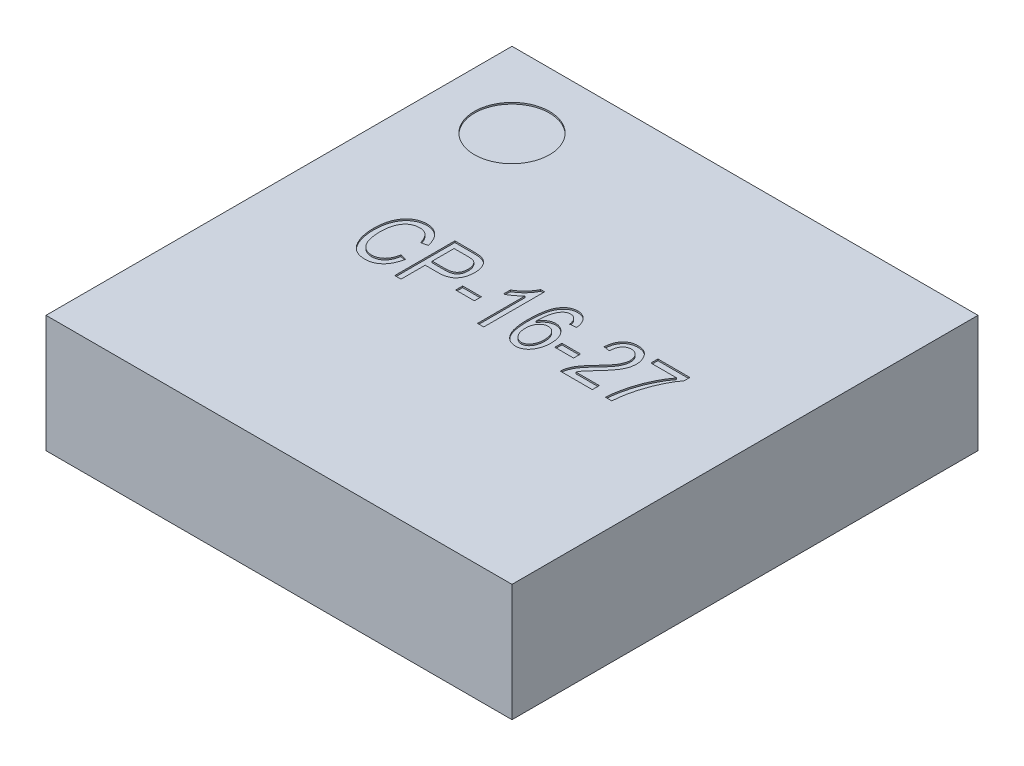
from build123d import *

# Parameters (mm, degrees)
SKETCH1_W           = 3.1
SKETCH1_H           = 3.1
BOSS_EXTRUDE1_DEPTH = 0.78
SKETCH2_R           = 0.25
CUT_EXTRUDE1_DEPTH  = 0.01
SKETCH3_W           = 0.124675325
SKETCH3_H           = 0.046753246
SKETCH3_W_2         = 0.124675324
CUT_EXTRUDE2_DEPTH  = 0.01


with BuildPart() as part:
    # Sketch1 → Boss-Extrude1 (new body)
    with BuildSketch(Plane(origin=(0, 0, 0), x_dir=(1, 0, 0), z_dir=(0, 1, 0))):
        Rectangle(SKETCH1_W, SKETCH1_H)
    extrude(amount=BOSS_EXTRUDE1_DEPTH)

    # Sketch2 → Cut-Extrude1 (cut)
    with BuildSketch(Plane(origin=(0, 0.78, 0), x_dir=(1, 0, 0), z_dir=(0, 1, 0))):
        with Locations(Location((-1.05, 1.05, 0), (0, 0, 270))):
            Circle(SKETCH2_R)
    extrude(amount=-CUT_EXTRUDE1_DEPTH, mode=Mode.SUBTRACT)

    # Sketch3 → Cut-Extrude2 (cut)
    with BuildSketch(Plane(origin=(0, 0.78, 0), x_dir=(1, 0, 0), z_dir=(0, 1, 0))):
        with BuildLine():
            Line((-0.717673959, -0.020779948), (-0.676115518, -0.031169558))
            add(Edge.make_bspline(
                [(-0.676115518, -0.031169558), (-0.677354174, -0.036676814), (-0.679769038, -0.047413667), (-0.684298524, -0.062856768), (-0.689591329, -0.077189165), (-0.695502514, -0.090465155), (-0.702079477, -0.102686775), (-0.709289846, -0.113845617), (-0.717194315, -0.123932561), (-0.725832256, -0.132823394), (-0.734915321, -0.140800826), (-0.744655072, -0.147497105), (-0.754758483, -0.153365781), (-0.765418597, -0.158039928), (-0.776527815, -0.161742072), (-0.788145945, -0.164295984), (-0.800225781, -0.166007418), (-0.808468802, -0.166158177), (-0.812641492, -0.166234493)],
                knots=[0, 0, 0, 0, 1.289221957, 2.51344498, 3.673011535, 4.776835723, 5.830430132, 6.840130389, 7.808269491, 8.7523986, 9.668123701, 10.564817631, 11.447926293, 12.333367568, 13.218722559, 14.118350969, 15.047492789, 16, 16, 16, 16], degree=3))
            add(Edge.make_bspline(
                [(-0.812641492, -0.166234493), (-0.81632424, -0.166183676), (-0.823543289, -0.166084064), (-0.834167116, -0.164958006), (-0.844408057, -0.163313188), (-0.854242401, -0.160836879), (-0.863691814, -0.157805377), (-0.872665062, -0.153912047), (-0.881307951, -0.149481171), (-0.889521557, -0.14424478), (-0.897403466, -0.138312627), (-0.904742149, -0.131415268), (-0.911892587, -0.12387567), (-0.918488354, -0.115333566), (-0.924977175, -0.106129517), (-0.930810714, -0.095919385), (-0.936469943, -0.085001883), (-0.941681628, -0.073289224), (-0.946535965, -0.060899189), (-0.950500155, -0.047813383), (-0.954035766, -0.034259551), (-0.956841804, -0.020132643), (-0.959157024, -0.005491351), (-0.960623158, 0.009743789), (-0.961659393, 0.02549902), (-0.961772365, 0.036198775), (-0.961829804, 0.041638884)],
                knots=[0, 0, 0, 0, 0.921095259, 1.805562833, 2.670327692, 3.514278933, 4.340642213, 5.150451062, 5.958900505, 6.768369716, 7.58482939, 8.423223242, 9.285360719, 10.181948201, 11.120907027, 12.10087379, 13.121233649, 14.196976745, 15.307105309, 16.44839936, 17.61583717, 18.810746038, 20.050660639, 21.323136918, 22.638994396, 24, 24, 24, 24], degree=3))
            add(Edge.make_bspline(
                [(-0.961829804, 0.041638884), (-0.961772834, 0.046997877), (-0.961661099, 0.057508534), (-0.960626561, 0.072939476), (-0.959164157, 0.087770654), (-0.956840779, 0.101951163), (-0.954053936, 0.115542709), (-0.950531524, 0.128454837), (-0.946508013, 0.140793776), (-0.941723576, 0.152441526), (-0.936332132, 0.163407368), (-0.930570922, 0.173736932), (-0.924426592, 0.183431155), (-0.917758506, 0.192390728), (-0.910602263, 0.200593407), (-0.903015944, 0.208121334), (-0.894960156, 0.214927688), (-0.886528111, 0.221135633), (-0.877692098, 0.226516011), (-0.868634351, 0.231294088), (-0.859286729, 0.235258605), (-0.849683347, 0.238516414), (-0.839833487, 0.241048803), (-0.829733439, 0.242789944), (-0.819408636, 0.244018013), (-0.812428714, 0.244109146), (-0.808907726, 0.244155117)],
                knots=[0, 0, 0, 0, 1.355009242, 2.657595594, 3.909622363, 5.12221665, 6.289669639, 7.416642245, 8.504963989, 9.569716403, 10.597874851, 11.593392335, 12.559484071, 13.498222117, 14.414780627, 15.309839368, 16.198178116, 17.079506653, 17.954919271, 18.811820418, 19.667108407, 20.519600343, 21.37423126, 22.235899437, 23.110108003, 24, 24, 24, 24], degree=3))
            add(Edge.make_bspline(
                [(-0.808907726, 0.244155117), (-0.8050623, 0.24405556), (-0.797508578, 0.243859996), (-0.786351382, 0.242490504), (-0.775678273, 0.239999719), (-0.765309714, 0.236790752), (-0.755440282, 0.232452785), (-0.745942459, 0.22723389), (-0.736899084, 0.221024065), (-0.728304253, 0.21386156), (-0.720167297, 0.205835035), (-0.71267253, 0.196860406), (-0.705888371, 0.186977463), (-0.699551163, 0.176324582), (-0.694092991, 0.164642114), (-0.689171716, 0.152135505), (-0.684691013, 0.138783402), (-0.682456143, 0.129456504), (-0.681310323, 0.124674598)],
                knots=[0, 0, 0, 0, 0.969230344, 1.90389736, 2.827024372, 3.728538081, 4.635631584, 5.539103428, 6.456494714, 7.396000419, 8.355610671, 9.333534695, 10.338037519, 11.374284513, 12.454112223, 13.583699076, 14.761161004, 16, 16, 16, 16], degree=3))
            Line((-0.681310323, 0.124674598), (-0.722868765, 0.114284988))
            add(Edge.make_bspline(
                [(-0.722868765, 0.114284988), (-0.72380807, 0.1176505), (-0.725639998, 0.124214261), (-0.728899965, 0.133641822), (-0.732465473, 0.142425695), (-0.736340493, 0.150589596), (-0.740655642, 0.158062682), (-0.745284801, 0.164905852), (-0.750235891, 0.171138158), (-0.755612907, 0.176628184), (-0.761236894, 0.181581722), (-0.76728019, 0.185825198), (-0.773692617, 0.18937023), (-0.780416229, 0.192350261), (-0.787472275, 0.194591776), (-0.794883956, 0.196242816), (-0.802631572, 0.197216684), (-0.807930987, 0.197339653), (-0.810612271, 0.197401871)],
                knots=[0, 0, 0, 0, 1.274827499, 2.486296693, 3.637698816, 4.732866786, 5.781146847, 6.783409552, 7.745577291, 8.681189198, 9.583979081, 10.476943643, 11.369744444, 12.253932728, 13.156290603, 14.066553906, 15.021756508, 16, 16, 16, 16], degree=3))
            add(Edge.make_bspline(
                [(-0.810612271, 0.197401871), (-0.815904597, 0.197205795), (-0.826231767, 0.196823184), (-0.841167984, 0.19364057), (-0.855065291, 0.188549857), (-0.865642596, 0.18244131), (-0.873485039, 0.1765823), (-0.8790439, 0.171573297), (-0.884278054, 0.165981379), (-0.88925122, 0.159859797), (-0.893962069, 0.153158481), (-0.898210259, 0.14579585), (-0.902330248, 0.137980778), (-0.906042798, 0.129546448), (-0.909350181, 0.120539235), (-0.912291901, 0.110978633), (-0.91480087, 0.100847723), (-0.916824723, 0.090115667), (-0.918329522, 0.078812809), (-0.919489715, 0.066929851), (-0.92011269, 0.054470253), (-0.920217822, 0.045968498), (-0.920271362, 0.041638884)],
                knots=[0, 0, 0, 0, 1.477189771, 2.882511776, 4.245778241, 5.596752156, 6.277022015, 6.978177212, 7.684002091, 8.414723124, 9.180080371, 9.969542299, 10.787683758, 11.647234596, 12.541638645, 13.466905688, 14.440346501, 15.45581228, 16.516221105, 17.624831929, 18.790418795, 20, 20, 20, 20], degree=3))
            add(Edge.make_bspline(
                [(-0.920271362, 0.041638884), (-0.920168702, 0.035143341), (-0.919969584, 0.022544756), (-0.918699933, 0.004247502), (-0.916478606, -0.012816545), (-0.913217695, -0.028590499), (-0.909189779, -0.04312512), (-0.904289195, -0.056425968), (-0.898330184, -0.0684372), (-0.891522297, -0.079183802), (-0.8839263, -0.088658019), (-0.875730678, -0.096912605), (-0.866883707, -0.103863227), (-0.857492839, -0.109642471), (-0.847418247, -0.114013812), (-0.836801386, -0.117211372), (-0.825560827, -0.119108196), (-0.817870604, -0.119355071), (-0.813940193, -0.119481246)],
                knots=[0, 0, 0, 0, 1.437104972, 2.787371166, 4.055570009, 5.241294904, 6.348053785, 7.389870239, 8.372351441, 9.308936623, 10.198930124, 11.053953419, 11.87666206, 12.682560998, 13.486679433, 14.299132302, 15.130700221, 16, 16, 16, 16], degree=3))
            add(Edge.make_bspline(
                [(-0.813940193, -0.119481246), (-0.811014145, -0.119400771), (-0.805248048, -0.119242185), (-0.796747241, -0.118057584), (-0.788524694, -0.116225847), (-0.780601242, -0.113537507), (-0.773062221, -0.109994091), (-0.765755503, -0.105868634), (-0.758832043, -0.100841487), (-0.752195034, -0.095122183), (-0.745980993, -0.088580795), (-0.740300252, -0.081224182), (-0.735067112, -0.073112295), (-0.730577755, -0.064111069), (-0.726495445, -0.054409126), (-0.722931815, -0.043917039), (-0.719923383, -0.032634868), (-0.718435825, -0.024795133), (-0.717673959, -0.020779948)],
                knots=[0, 0, 0, 0, 0.928044623, 1.828813311, 2.717973564, 3.597468745, 4.476963925, 5.35746386, 6.25552913, 7.186585864, 8.133765821, 9.112470931, 10.131597503, 11.191133367, 12.299110282, 13.469062082, 14.703759174, 16, 16, 16, 16], degree=3))
        make_face()
        with BuildLine():
            Line((-0.618972661, -0.161039688), (-0.618972661, 0.238960312))
            Line((-0.618972661, 0.238960312), (-0.495758375, 0.238960312))
            add(Edge.make_bspline(
                [(-0.495758375, 0.238960312), (-0.492240314, 0.238963613), (-0.485472091, 0.238969965), (-0.475679081, 0.238490847), (-0.466574415, 0.238006712), (-0.458190029, 0.237072543), (-0.450519579, 0.236052464), (-0.4435709, 0.234777753), (-0.437342604, 0.233166734), (-0.433468402, 0.231865202), (-0.431634998, 0.231249273)],
                knots=[0, 0, 0, 0, 1.301145482, 2.503209419, 3.626350361, 4.67304202, 5.622796861, 6.488461115, 7.284688674, 8, 8, 8, 8], degree=3))
            add(Edge.make_bspline(
                [(-0.431634998, 0.231249273), (-0.429313442, 0.230350704), (-0.42467583, 0.228555696), (-0.418143488, 0.225011983), (-0.411912081, 0.221019634), (-0.40605223, 0.216474638), (-0.400598305, 0.211306944), (-0.395464933, 0.205630096), (-0.390754102, 0.199327392), (-0.386413721, 0.192533074), (-0.382372156, 0.185315688), (-0.379035184, 0.177586977), (-0.37603759, 0.169509889), (-0.373756879, 0.160989821), (-0.371829461, 0.152087041), (-0.370601848, 0.142774567), (-0.369726879, 0.133051683), (-0.369657499, 0.12643538), (-0.369622011, 0.123051221)],
                knots=[0, 0, 0, 0, 0.897158766, 1.79219156, 2.674738776, 3.564969572, 4.462552928, 5.381685756, 6.322532571, 7.297145314, 8.28871417, 9.302465757, 10.330585605, 11.393732126, 12.480975679, 13.614163778, 14.779673607, 16, 16, 16, 16], degree=3))
            add(Edge.make_bspline(
                [(-0.369622011, 0.123051221), (-0.369690722, 0.118610797), (-0.369825104, 0.109926368), (-0.371144526, 0.097224331), (-0.373337363, 0.085180996), (-0.376329255, 0.073738505), (-0.380214936, 0.062914139), (-0.385026496, 0.052736343), (-0.390671021, 0.043168667), (-0.397115059, 0.034193258), (-0.40470874, 0.02602347), (-0.413670766, 0.019034277), (-0.423810505, 0.013056681), (-0.435254535, 0.008305428), (-0.447886121, 0.004467699), (-0.461819778, 0.001851467), (-0.47700167, 0.000336184), (-0.48752964, 0.000114455), (-0.492998635, -7.27e-07)],
                knots=[0, 0, 0, 0, 1.066125632, 2.085091685, 3.062630143, 4.003547869, 4.922307223, 5.820454748, 6.703048758, 7.586837887, 8.469431897, 9.371589709, 10.306565591, 11.287746888, 12.340181319, 13.471797101, 14.68666727, 16, 16, 16, 16], degree=3))
            Line((-0.492998635, -7.27e-07), (-0.577414219, -7.27e-07))
            Line((-0.577414219, -7.27e-07), (-0.577414219, -0.161039688))
            Line((-0.577414219, -0.161039688), (-0.618972661, -0.161039688))
        make_face()
        with BuildLine():
            Line((-0.577414219, 0.04675252), (-0.490401232, 0.04675252))
            add(Edge.make_bspline(
                [(-0.490401232, 0.04675252), (-0.487099134, 0.046826708), (-0.480701285, 0.046970447), (-0.471415073, 0.047737122), (-0.462813342, 0.049199343), (-0.454898878, 0.051201765), (-0.447693712, 0.053812929), (-0.441161902, 0.056952754), (-0.435340741, 0.06073189), (-0.430138529, 0.065051426), (-0.425704662, 0.070070248), (-0.421716201, 0.075537236), (-0.418481657, 0.081710535), (-0.415838354, 0.088443657), (-0.413691262, 0.095714653), (-0.412274594, 0.103579963), (-0.411369075, 0.112018172), (-0.411244576, 0.11785394), (-0.411180453, 0.120859663)],
                knots=[0, 0, 0, 0, 1.269306236, 2.459294321, 3.577321076, 4.618943517, 5.592639886, 6.518111891, 7.397820391, 8.253919533, 9.107995395, 9.965041305, 10.848919063, 11.777714976, 12.741869721, 13.757527659, 14.845010431, 16, 16, 16, 16], degree=3))
            add(Edge.make_bspline(
                [(-0.411180453, 0.120859663), (-0.41127277, 0.124763875), (-0.41145141, 0.13231875), (-0.413299208, 0.143185683), (-0.41615756, 0.153210175), (-0.420340943, 0.162190584), (-0.425233361, 0.170065524), (-0.430590526, 0.176801966), (-0.436573807, 0.182094429), (-0.442142264, 0.185393085), (-0.447032588, 0.187473479), (-0.451390533, 0.188757306), (-0.456422709, 0.189765719), (-0.462110953, 0.190648777), (-0.468444185, 0.191393368), (-0.475434491, 0.191832062), (-0.483092334, 0.192192058), (-0.488425602, 0.192201914), (-0.491212921, 0.192207065)],
                knots=[0, 0, 0, 0, 1.500314686, 2.903195123, 4.226916567, 5.498136997, 6.699407891, 7.786731959, 8.797026544, 9.75363827, 10.261964553, 10.838097333, 11.497334866, 12.234733717, 13.051831226, 13.948971176, 14.928073425, 16, 16, 16, 16], degree=3))
            Line((-0.491212921, 0.192207065), (-0.577414219, 0.192207065))
            Line((-0.577414219, 0.192207065), (-0.577414219, 0.04675252))
        make_face(mode=Mode.SUBTRACT)
        with Locations((-0.270920712, -0.018182545)):
            Rectangle(SKETCH3_W, SKETCH3_H)
        with BuildLine():
            Line((-0.026764869, -0.161039688), (-0.06832331, -0.161039688))
            Line((-0.06832331, -0.161039688), (-0.06832331, 0.155843429))
            add(Edge.make_bspline(
                [(-0.06832331, 0.155843429), (-0.070875566, 0.152905564), (-0.076165113, 0.146816842), (-0.085347495, 0.13815783), (-0.095580246, 0.129228622), (-0.10690926, 0.120564136), (-0.118452624, 0.112264961), (-0.12985384, 0.104965691), (-0.140685597, 0.098614777), (-0.147952178, 0.095162761), (-0.151440193, 0.093505767)],
                knots=[0, 0, 0, 0, 0.892555828, 1.849821039, 2.893015883, 4.008277588, 5.121255548, 6.154629642, 7.114207698, 8, 8, 8, 8], degree=3))
            Line((-0.151440193, 0.093505767), (-0.151440193, 0.140259014))
            add(Edge.make_bspline(
                [(-0.151440193, 0.140259014), (-0.145834671, 0.14363263), (-0.134671624, 0.150350977), (-0.119030735, 0.161989322), (-0.104254989, 0.174551002), (-0.090786029, 0.188167636), (-0.078726056, 0.202204347), (-0.068374703, 0.216213002), (-0.059887249, 0.230044761), (-0.055723882, 0.239559415), (-0.053712921, 0.244155117)],
                knots=[0, 0, 0, 0, 1.082272232, 2.155277244, 3.222407096, 4.289527553, 5.32168536, 6.282742408, 7.170542132, 8, 8, 8, 8], degree=3))
            Line((-0.053712921, 0.244155117), (-0.026764869, 0.244155117))
            Line((-0.026764869, 0.244155117), (-0.026764869, -0.161039688))
        make_face()
        with BuildLine():
            Line((0.284923443, 0.145453819), (0.243365002, 0.140259014))
            add(Edge.make_bspline(
                [(0.243365002, 0.140259014), (0.242404381, 0.144992087), (0.240605578, 0.153854966), (0.236703996, 0.165861359), (0.232356913, 0.17589986), (0.228336902, 0.181226419), (0.226481885, 0.183684338)],
                knots=[0, 0, 0, 0, 1.230211225, 2.30362229, 3.217213433, 4, 4, 4, 4], degree=3))
            add(Edge.make_bspline(
                [(0.226481885, 0.183684338), (0.22513288, 0.185202779), (0.222509849, 0.188155267), (0.218150359, 0.191979815), (0.213661907, 0.19527595), (0.20894171, 0.197989944), (0.203934127, 0.20001908), (0.198732377, 0.201471453), (0.193343338, 0.202397364), (0.189689017, 0.202529844), (0.187845521, 0.202596676)],
                knots=[0, 0, 0, 0, 1.09495211, 2.12904747, 3.12182315, 4.09596367, 5.058329339, 6.028853599, 7.005615717, 8, 8, 8, 8], degree=3))
            add(Edge.make_bspline(
                [(0.187845521, 0.202596676), (0.184989644, 0.202490714), (0.179331577, 0.202280783), (0.171120534, 0.200017519), (0.163303633, 0.196619116), (0.155990207, 0.191704063), (0.149166308, 0.185446187), (0.142686713, 0.177904516), (0.136795121, 0.168905933), (0.13337495, 0.162289198), (0.131595521, 0.158846676)],
                knots=[0, 0, 0, 0, 0.906800098, 1.796553483, 2.691003266, 3.610512055, 4.585978966, 5.630213089, 6.767058994, 8, 8, 8, 8], degree=3))
            add(Edge.make_bspline(
                [(0.131595521, 0.158846676), (0.130102074, 0.155542363), (0.126997164, 0.148672624), (0.123356189, 0.137477648), (0.120156634, 0.125207837), (0.117757555, 0.111756056), (0.115576404, 0.09726168), (0.114185729, 0.081595701), (0.113276825, 0.064836984), (0.113152859, 0.053274407), (0.113089028, 0.047320702)],
                knots=[0, 0, 0, 0, 0.763508889, 1.587351645, 2.476402758, 3.433472996, 4.464603951, 5.563935012, 6.745641893, 8, 8, 8, 8], degree=3))
            add(Edge.make_bspline(
                [(0.113089028, 0.047320702), (0.115442115, 0.051372008), (0.120020764, 0.059255059), (0.128552765, 0.069583835), (0.137700859, 0.078585416), (0.14785932, 0.085818365), (0.158582213, 0.091493247), (0.169660689, 0.09569875), (0.18110235, 0.098236024), (0.188834183, 0.098545308), (0.192715651, 0.098700572)],
                knots=[0, 0, 0, 0, 1.127907175, 2.194687167, 3.21896757, 4.214740698, 5.189497801, 6.137088422, 7.064797308, 8, 8, 8, 8], degree=3))
            add(Edge.make_bspline(
                [(0.192715651, 0.098700572), (0.195942089, 0.098588339), (0.20230119, 0.098367134), (0.211685044, 0.096693105), (0.220718449, 0.093909254), (0.22948525, 0.09008067), (0.237898309, 0.085045758), (0.246017346, 0.078963334), (0.25374048, 0.071707651), (0.26120294, 0.063595065), (0.267977261, 0.054456662), (0.273918887, 0.044501224), (0.278988983, 0.033833036), (0.28301306, 0.022357644), (0.286275993, 0.010211465), (0.288540948, -0.002716139), (0.289809994, -0.016371156), (0.290013858, -0.025728629), (0.290118248, -0.030520207)],
                knots=[0, 0, 0, 0, 0.860357646, 1.695709716, 2.533583491, 3.377064945, 4.241047709, 5.143225219, 6.077846286, 7.063889573, 8.080111547, 9.106229702, 10.152257742, 11.225204373, 12.345649275, 13.503769734, 14.721782881, 16, 16, 16, 16], degree=3))
            add(Edge.make_bspline(
                [(0.290118248, -0.030520207), (0.289952534, -0.037022742), (0.289627917, -0.049760509), (0.286907185, -0.068410475), (0.28232662, -0.086101868), (0.277134791, -0.100123004), (0.272147512, -0.110632908), (0.268154187, -0.117971254), (0.263950002, -0.124788088), (0.259498718, -0.131095099), (0.254665001, -0.136745181), (0.249713854, -0.142014415), (0.244446664, -0.146715534), (0.237146383, -0.152171692), (0.227543661, -0.15780978), (0.215276647, -0.16263767), (0.202442029, -0.165689331), (0.193652304, -0.166051891), (0.189225391, -0.166234493)],
                knots=[0, 0, 0, 0, 1.657459496, 3.246784879, 4.79287916, 6.310074839, 7.050696599, 7.757650882, 8.439205885, 9.092012499, 9.723586031, 10.333538589, 10.934530017, 11.52093132, 12.655638276, 13.761218907, 14.872446044, 16, 16, 16, 16], degree=3))
            add(Edge.make_bspline(
                [(0.189225391, -0.166234493), (0.185237855, -0.166095138), (0.177394951, -0.165821045), (0.165918694, -0.163617822), (0.154941892, -0.160170054), (0.144586886, -0.155093965), (0.134627172, -0.148849952), (0.125409214, -0.140948709), (0.116653517, -0.131760098), (0.108392087, -0.12118391), (0.10096222, -0.108858106), (0.094479613, -0.094737112), (0.089063674, -0.078708246), (0.084796278, -0.06080973), (0.081295975, -0.041082241), (0.078835172, -0.019506574), (0.077386589, 0.003956431), (0.077218544, 0.02020814), (0.077131235, 0.028651871)],
                knots=[0, 0, 0, 0, 0.760819453, 1.496421576, 2.223429687, 2.951263266, 3.692179274, 4.462099387, 5.262291211, 6.1127328, 7.019077074, 8.003719522, 9.073773746, 10.244022616, 11.513769144, 12.897217303, 14.387919526, 16, 16, 16, 16], degree=3))
            add(Edge.make_bspline(
                [(0.077131235, 0.028651871), (0.077208084, 0.038015949), (0.077356122, 0.056054395), (0.078945203, 0.082077491), (0.081349651, 0.106014513), (0.084930615, 0.127856202), (0.089374002, 0.147637767), (0.09496505, 0.165316612), (0.101454591, 0.18097004), (0.109175223, 0.194497145), (0.117686903, 0.206172955), (0.126706652, 0.216301395), (0.136258891, 0.224957018), (0.146447135, 0.232014826), (0.157298195, 0.237398252), (0.168651764, 0.241365443), (0.18063792, 0.243662468), (0.188809992, 0.243989218), (0.192959157, 0.244155117)],
                knots=[0, 0, 0, 0, 1.648816343, 3.176189159, 4.589499976, 5.883521052, 7.071677735, 8.156616623, 9.145117633, 10.049911772, 10.892392766, 11.685345428, 12.434380955, 13.15730553, 13.86047472, 14.561137348, 15.269453316, 16, 16, 16, 16], degree=3))
            add(Edge.make_bspline(
                [(0.192959157, 0.244155117), (0.195965137, 0.244069348), (0.20189051, 0.243900279), (0.210609882, 0.242796258), (0.218910294, 0.240719044), (0.22686885, 0.237968555), (0.234409704, 0.234365022), (0.241648801, 0.230070445), (0.248364103, 0.224789827), (0.254792183, 0.218891267), (0.260739652, 0.212236418), (0.266026766, 0.20477952), (0.270715457, 0.196637966), (0.274910986, 0.187814506), (0.278358522, 0.178232841), (0.281177012, 0.167939369), (0.283493772, 0.15696726), (0.284438537, 0.149358865), (0.284923443, 0.145453819)],
                knots=[0, 0, 0, 0, 0.965625992, 1.903437499, 2.816107718, 3.709373219, 4.603483816, 5.496241877, 6.407089735, 7.341876361, 8.295975248, 9.267838192, 10.27248647, 11.310449055, 12.401896837, 13.538363143, 14.736552469, 16, 16, 16, 16], degree=3))
        make_face()
        with BuildLine():
            add(Edge.make_bspline(
                [(0.118689677, -0.028977999), (0.118749014, -0.032497546), (0.118864734, -0.039361354), (0.119853435, -0.049399814), (0.121485447, -0.058884753), (0.123626193, -0.067900686), (0.126588555, -0.076319236), (0.130055191, -0.084294838), (0.134302341, -0.091657447), (0.139075654, -0.098483074), (0.14428973, -0.104580223), (0.149791127, -0.109917168), (0.155429514, -0.11449839), (0.161370673, -0.1181746), (0.167456988, -0.121171157), (0.173840405, -0.123166607), (0.180380638, -0.12444806), (0.184809258, -0.12459982), (0.187033833, -0.124676051)],
                knots=[0, 0, 0, 0, 1.295936842, 2.527331243, 3.710032566, 4.838610101, 5.935196688, 6.992417297, 8.036740745, 9.059547266, 10.056000021, 10.986130286, 11.879343137, 12.725347321, 13.554280309, 14.370418864, 15.181432095, 16, 16, 16, 16], degree=3))
            add(Edge.make_bspline(
                [(0.187033833, -0.124676051), (0.189013542, -0.124590756), (0.19295121, -0.124421103), (0.198758244, -0.12328018), (0.204346119, -0.121254641), (0.209829558, -0.118589855), (0.215095823, -0.115034677), (0.220263519, -0.11082117), (0.225094553, -0.105682273), (0.229918088, -0.100001507), (0.234231988, -0.093491126), (0.23820131, -0.086465866), (0.241289997, -0.078727844), (0.244036308, -0.070539827), (0.245987497, -0.061686922), (0.247594358, -0.052325026), (0.248334046, -0.042328362), (0.248483048, -0.035499281), (0.248559807, -0.031981246)],
                knots=[0, 0, 0, 0, 0.772594522, 1.536700729, 2.298102904, 3.086693685, 3.909598938, 4.772126543, 5.683120767, 6.657848237, 7.676972593, 8.726121203, 9.800678132, 10.92259173, 12.09308983, 13.334225679, 14.626713094, 16, 16, 16, 16], degree=3))
            add(Edge.make_bspline(
                [(0.248559807, -0.031981246), (0.248485898, -0.028543912), (0.248342527, -0.021876017), (0.247565358, -0.012132311), (0.246094323, -0.002996088), (0.24412264, 0.005581856), (0.241379815, 0.013475632), (0.238260601, 0.020861288), (0.234413761, 0.027618281), (0.230035078, 0.033767478), (0.225290998, 0.039274526), (0.220184837, 0.044039798), (0.214876432, 0.048106772), (0.209246448, 0.051392313), (0.203419494, 0.054042492), (0.19722881, 0.055783043), (0.190842801, 0.057001835), (0.1864715, 0.057095198), (0.184274092, 0.05714213)],
                knots=[0, 0, 0, 0, 1.343777819, 2.606719898, 3.816838752, 4.958326899, 6.041908764, 7.079242616, 8.08798765, 9.073968097, 10.026073332, 10.923948235, 11.799625043, 12.633965371, 13.467232591, 14.293828985, 15.142325764, 16, 16, 16, 16], degree=3))
            add(Edge.make_bspline(
                [(0.184274092, 0.05714213), (0.182103357, 0.057097139), (0.177811686, 0.057008187), (0.17153656, 0.055772906), (0.165428891, 0.054031673), (0.159592558, 0.051355641), (0.15387572, 0.048126024), (0.148381896, 0.044114019), (0.143230833, 0.039255851), (0.138183726, 0.033870951), (0.133586612, 0.02782469), (0.129586606, 0.021213406), (0.126264981, 0.014094893), (0.123491594, 0.006492253), (0.121290723, -0.001649346), (0.119782576, -0.010316723), (0.118882514, -0.019489268), (0.118755153, -0.025756207), (0.118689677, -0.028977999)],
                knots=[0, 0, 0, 0, 0.863470541, 1.707132358, 2.539352989, 3.38871181, 4.257816365, 5.15261427, 6.090962397, 7.075009843, 8.09049846, 9.111009759, 10.147788812, 11.215218178, 12.331811356, 13.503305971, 14.716465586, 16, 16, 16, 16], degree=3))
        make_face(mode=Mode.SUBTRACT)
        with Locations((0.388819547, -0.018182545)):
            Rectangle(SKETCH3_W_2, SKETCH3_H)
        with BuildLine():
            Line((0.695313054, -0.114286441), (0.695313054, -0.161039688))
            Line((0.695313054, -0.161039688), (0.482326041, -0.161039688))
            add(Edge.make_bspline(
                [(0.482326041, -0.161039688), (0.482316179, -0.158603648), (0.4822962, -0.153668192), (0.482960453, -0.146143653), (0.484325218, -0.13843694), (0.486067883, -0.130445246), (0.488538793, -0.122273677), (0.491563645, -0.113882529), (0.495132704, -0.105292692), (0.499311746, -0.096453294), (0.504195168, -0.087279546), (0.510088042, -0.07780983), (0.516860417, -0.067874281), (0.524521247, -0.057533467), (0.53322036, -0.046885461), (0.542699559, -0.035772192), (0.553094123, -0.024216809), (0.560495075, -0.016536995), (0.56430656, -0.012581896)],
                knots=[0, 0, 0, 0, 0.672188691, 1.361865275, 2.08134618, 2.831455259, 3.618325166, 4.435686407, 5.292818481, 6.184803937, 7.133719261, 8.159707436, 9.261705982, 10.452168352, 11.710682541, 13.056179633, 14.483934645, 16, 16, 16, 16], degree=3))
            add(Edge.make_bspline(
                [(0.56430656, -0.012581896), (0.568735933, -0.008000468), (0.577264345, 0.000820716), (0.589267271, 0.013845733), (0.600173135, 0.025952326), (0.609764045, 0.037359415), (0.618210274, 0.04791164), (0.625596801, 0.057593915), (0.631570623, 0.066625971), (0.638020652, 0.077253482), (0.644169839, 0.089905366), (0.649606068, 0.104653138), (0.653118569, 0.118909845), (0.653546725, 0.128308988), (0.653754612, 0.13287265)],
                knots=[0, 0, 0, 0, 1.312560889, 2.527233899, 3.64818266, 4.668586789, 5.596397896, 6.432357998, 7.175835261, 7.825761013, 8.992224112, 10.065918602, 11.060925749, 12, 12, 12, 12], degree=3))
            add(Edge.make_bspline(
                [(0.653754612, 0.13287265), (0.653725625, 0.135392154), (0.65366901, 0.14031301), (0.652706923, 0.147499394), (0.651334859, 0.154334759), (0.649523329, 0.160868503), (0.646954788, 0.166993311), (0.643877242, 0.172751675), (0.640272334, 0.178169676), (0.636158587, 0.183167749), (0.63162206, 0.187676635), (0.626841196, 0.191727303), (0.621691627, 0.195005726), (0.616384999, 0.197859659), (0.610741993, 0.199928015), (0.604881435, 0.201504638), (0.598749103, 0.202393609), (0.594585207, 0.202528316), (0.592472144, 0.202596676)],
                knots=[0, 0, 0, 0, 1.164486654, 2.274364258, 3.346924328, 4.388668322, 5.404300818, 6.412115579, 7.404820287, 8.409522099, 9.400647826, 10.360464378, 11.301161788, 12.219192522, 13.141987859, 14.073903283, 15.022558797, 16, 16, 16, 16], degree=3))
            add(Edge.make_bspline(
                [(0.592472144, 0.202596676), (0.590193848, 0.20254888), (0.58574651, 0.20245558), (0.579264224, 0.201296116), (0.573053003, 0.199744983), (0.567144366, 0.19733931), (0.561581532, 0.194257789), (0.556284365, 0.190548593), (0.551356551, 0.186141609), (0.546698823, 0.181130341), (0.542615731, 0.175415907), (0.538866853, 0.169232265), (0.53591477, 0.162317475), (0.533404648, 0.154884757), (0.531438827, 0.146847468), (0.530124833, 0.13823592), (0.529161216, 0.129052214), (0.529107099, 0.122729283), (0.529079287, 0.119479793)],
                knots=[0, 0, 0, 0, 0.928788257, 1.813037313, 2.680996359, 3.53827917, 4.408273621, 5.272359245, 6.172129225, 7.102295458, 8.058839945, 9.034325244, 10.048074492, 11.120300332, 12.234644845, 13.420320921, 14.674247329, 16, 16, 16, 16], degree=3))
            Line((0.529079287, 0.119479793), (0.487520846, 0.124674598))
            add(Edge.make_bspline(
                [(0.487520846, 0.124674598), (0.487949126, 0.129497125), (0.488780008, 0.138853045), (0.490960013, 0.152397193), (0.493985162, 0.164963736), (0.497576203, 0.17667804), (0.502094146, 0.187394725), (0.507145349, 0.197308823), (0.513132235, 0.206204818), (0.5198086, 0.21419269), (0.527118534, 0.221279562), (0.535020835, 0.22739679), (0.543504774, 0.232553498), (0.552473462, 0.236889458), (0.562112287, 0.24012736), (0.57224833, 0.242477356), (0.582964028, 0.243869607), (0.590276502, 0.244058541), (0.594014352, 0.244155117)],
                knots=[0, 0, 0, 0, 1.296155121, 2.514599762, 3.669097984, 4.755193195, 5.79120272, 6.77953026, 7.729955905, 8.65570694, 9.562583864, 10.450894749, 11.325630111, 12.216772649, 13.112585423, 14.04224033, 14.999270054, 16, 16, 16, 16], degree=3))
            add(Edge.make_bspline(
                [(0.594014352, 0.244155117), (0.598050148, 0.244036651), (0.605908514, 0.243805977), (0.617348442, 0.24228602), (0.628018266, 0.239604919), (0.637965644, 0.235874125), (0.647071112, 0.230962637), (0.655482777, 0.225071173), (0.66306026, 0.218020639), (0.669803528, 0.209998126), (0.675762882, 0.20133686), (0.680962807, 0.192280155), (0.685473325, 0.182978078), (0.688998422, 0.173327123), (0.691942253, 0.163456815), (0.693791632, 0.15321753), (0.695093582, 0.142727413), (0.695239483, 0.135636526), (0.695313054, 0.132060962)],
                knots=[0, 0, 0, 0, 1.141256367, 2.222215694, 3.255808886, 4.246221905, 5.218350639, 6.173592628, 7.142736081, 8.136099926, 9.131465336, 10.11177911, 11.087094076, 12.050634184, 13.014356534, 13.995714735, 14.989343724, 16, 16, 16, 16], degree=3))
            add(Edge.make_bspline(
                [(0.695313054, 0.132060962), (0.695243736, 0.128839535), (0.695106005, 0.122438652), (0.694210049, 0.112888171), (0.692628521, 0.103466089), (0.690574977, 0.094081809), (0.687660984, 0.084880635), (0.684362188, 0.075716428), (0.680361005, 0.066692573), (0.675637509, 0.057632927), (0.670106908, 0.048216891), (0.66347942, 0.038272611), (0.65587795, 0.027534273), (0.646993739, 0.016193211), (0.637257272, 0.003923287), (0.626238408, -0.008966332), (0.61415213, -0.02258931), (0.605636996, -0.031832937), (0.601238378, -0.03660787)],
                knots=[0, 0, 0, 0, 0.78053567, 1.550902233, 2.321464013, 3.094364546, 3.87611052, 4.657966429, 5.453363508, 6.265521698, 7.132350641, 8.097801917, 9.160103787, 10.319208993, 11.587678713, 12.955014444, 14.427067756, 16, 16, 16, 16], degree=3))
            add(Edge.make_bspline(
                [(0.601238378, -0.03660787), (0.598445985, -0.03957884), (0.593109497, -0.045256603), (0.585552391, -0.053472397), (0.57877095, -0.060946203), (0.572617529, -0.067572803), (0.56739634, -0.073575051), (0.562869632, -0.078794387), (0.559170964, -0.083295147), (0.553627821, -0.090370622), (0.546636482, -0.100339903), (0.54180632, -0.109738333), (0.539468898, -0.114286441)],
                knots=[0, 0, 0, 0, 1.227496676, 2.345844757, 3.360613726, 4.265798447, 5.068085109, 5.75545707, 6.345771879, 6.821573405, 8.46188917, 10, 10, 10, 10], degree=3))
            Line((0.539468898, -0.114286441), (0.695313054, -0.114286441))
        make_face()
        with BuildLine():
            Line((0.736871495, 0.18701226), (0.736871495, 0.233765507))
            Line((0.736871495, 0.233765507), (0.949858508, 0.233765507))
            Line((0.949858508, 0.233765507), (0.949858508, 0.195534988))
            add(Edge.make_bspline(
                [(0.949858508, 0.195534988), (0.945906766, 0.190244312), (0.93786318, 0.179475387), (0.92661445, 0.162249334), (0.915674577, 0.143903314), (0.905033306, 0.124421819), (0.894815651, 0.103742241), (0.884918496, 0.081929444), (0.87543423, 0.058901386), (0.866357058, 0.034950681), (0.857851051, 0.010454126), (0.850317092, -0.014216041), (0.843719811, -0.038821645), (0.838140722, -0.06336156), (0.833385947, -0.087823141), (0.829670159, -0.112249063), (0.826868258, -0.136645025), (0.825744229, -0.152917493), (0.825183183, -0.161039688)],
                knots=[0, 0, 0, 0, 0.828235292, 1.685834407, 2.579347319, 3.50739146, 4.469751317, 5.472290501, 6.511687755, 7.593421113, 8.685056077, 9.764080991, 10.828622054, 11.880069368, 12.920502423, 13.954003105, 14.978766756, 16, 16, 16, 16], degree=3))
            Line((0.825183183, -0.161039688), (0.783624742, -0.161039688))
            add(Edge.make_bspline(
                [(0.783624742, -0.161039688), (0.783753145, -0.156763021), (0.784015088, -0.148038621), (0.785065959, -0.134700178), (0.786390674, -0.120803437), (0.788375873, -0.106409749), (0.790816032, -0.091497441), (0.793781418, -0.076085346), (0.797053028, -0.060094594), (0.80229177, -0.038181512), (0.809675583, -0.010733656), (0.820286922, 0.021586819), (0.832249511, 0.053168527), (0.845864303, 0.083606817), (0.86038261, 0.112605537), (0.875671804, 0.13956087), (0.891287794, 0.164426304), (0.902730295, 0.179617681), (0.908300066, 0.18701226)],
                knots=[0, 0, 0, 0, 0.54755489, 1.117011975, 1.712111195, 2.334110413, 2.976306168, 3.645990646, 4.342828197, 5.06521062, 6.529487471, 7.979439287, 9.417531512, 10.850025522, 12.245424871, 13.566691952, 14.815558909, 16, 16, 16, 16], degree=3))
            Line((0.908300066, 0.18701226), (0.736871495, 0.18701226))
        make_face()
    extrude(amount=-CUT_EXTRUDE2_DEPTH, mode=Mode.SUBTRACT)


solid = part.part
